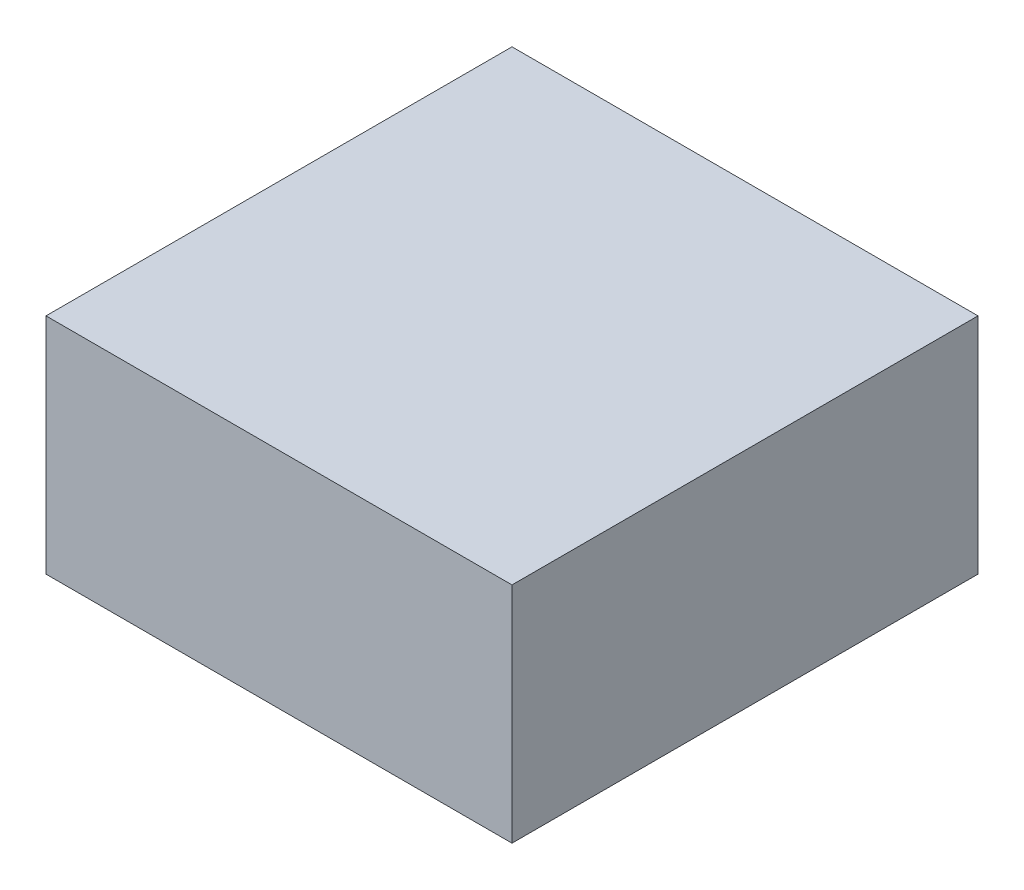
from build123d import *

# Parameters (mm, degrees)
SKETCH1_W           = 12.7
SKETCH1_H           = 12.7
BOSS_EXTRUDE1_DEPTH = 3.048


with BuildPart() as part:
    # Sketch1 → Boss-Extrude1 (new body, symmetric)
    with BuildSketch(Plane(origin=(0, 0, 0), x_dir=(1, 0, 0), z_dir=(0, 1, 0))):
        Rectangle(SKETCH1_W, SKETCH1_H)
    extrude(amount=BOSS_EXTRUDE1_DEPTH, both=True)


solid = part.part
